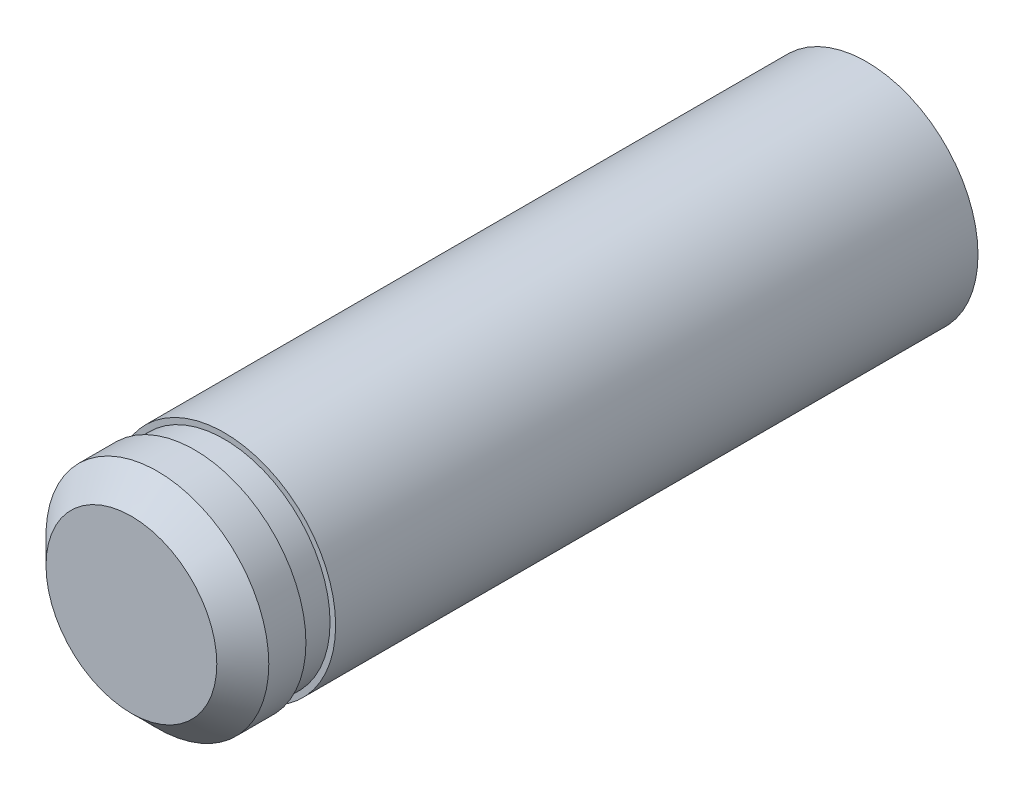
from build123d import *


with BuildPart() as part:
    # Sketch2 → Revolve1 (revolve)
    with BuildSketch(Plane(origin=(0, 0, 0), x_dir=(0, 0, -1), z_dir=(1, 0, 0))):
        Polygon((-18.1, 3), (-19.1, 3), (-19.8, 2.3), (-19.8, 0), (0, 0), (0, 3), (-17.3, 3), (-17.3, 2.85), (-18.1, 2.85), align=None)
    revolve(axis=Axis((0, 0, 0), (0, 0, -1)))


solid = part.part
